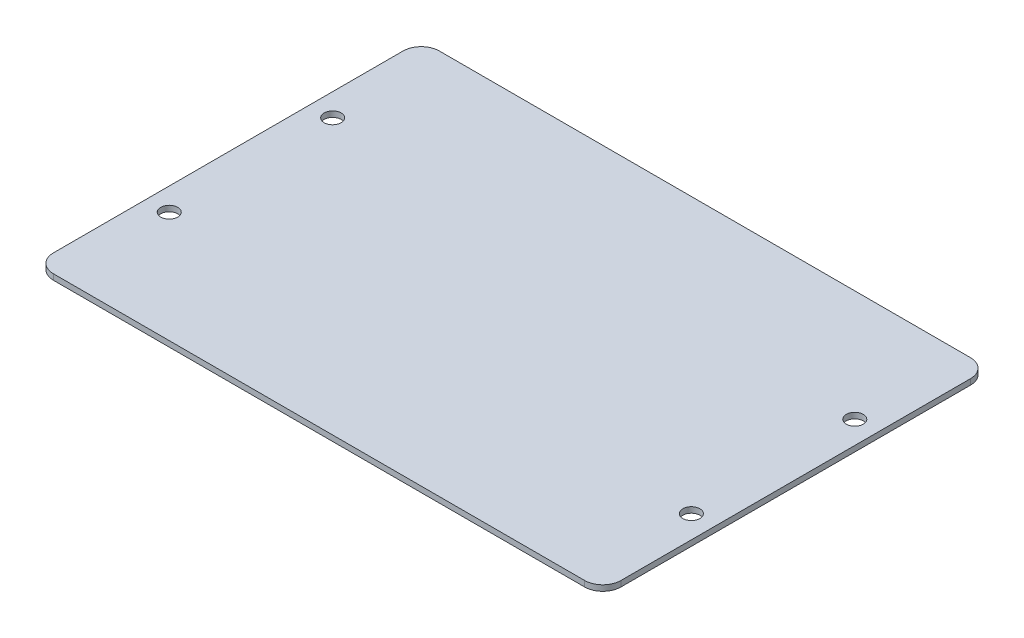
from build123d import *

# Parameters (mm, degrees)
SKETCH1_W           = 250
SKETCH1_H           = 170
BOSS_EXTRUDE1_DEPTH = 2.5
SKETCH2_R           = 3.75
CUT_EXTRUDE1_DEPTH  = 3.5
FILLET1_R           = 8
SKETCH4_W           = 40
SKETCH4_H           = 50
BOSS_EXTRUDE2_DEPTH = 15


with BuildPart() as part:
    # Sketch1 → Boss-Extrude1 (new body)
    with BuildSketch(Plane(origin=(0, 0, 0), x_dir=(1, 0, 0), z_dir=(0, 1, 0))):
        Rectangle(SKETCH1_W, SKETCH1_H)
    extrude(amount=BOSS_EXTRUDE1_DEPTH)

    # Sketch2 → Cut-Extrude1 (cut, through all)
    with BuildSketch(Plane(origin=(0, 2.5, 0), x_dir=(1, 0, 0), z_dir=(0, 1, 0))):
        with Locations((-115, 36)):
            Circle(SKETCH2_R)
        with Locations((-115, -36)):
            Circle(SKETCH2_R)
        with Locations((115, -36)):
            Circle(SKETCH2_R)
        with Locations((115, 36)):
            Circle(SKETCH2_R)
    extrude(amount=-CUT_EXTRUDE1_DEPTH, mode=Mode.SUBTRACT)

    # Fillet1
    fillet1_edges = [part.edges().sort_by_distance(p)[0] for p in [
        (-125, 1.25, -85),
        (125, 1.25, -85),
        (125, 1.25, 85),
        (-125, 1.25, 85),
    ]]
    fillet(fillet1_edges, radius=FILLET1_R)

    # Sketch4 → Boss-Extrude2 (add)
    with BuildSketch(Plane.XZ):
        with Locations((0, 16)):
            Rectangle(SKETCH4_W, SKETCH4_H)
    extrude(amount=BOSS_EXTRUDE2_DEPTH)


solid = part.part
